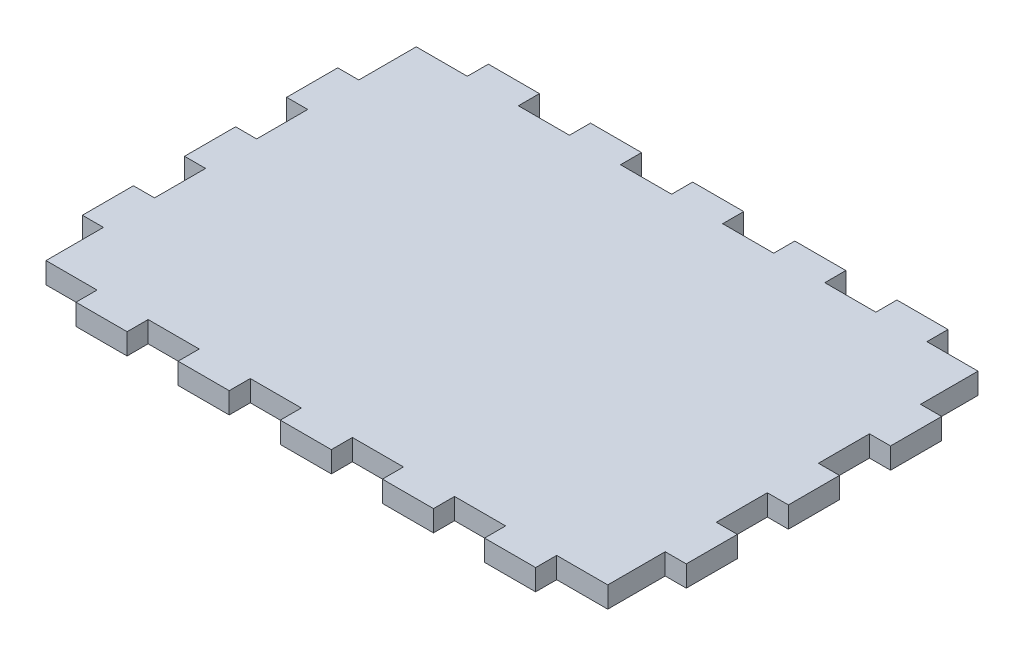
from build123d import *

# Parameters (mm, degrees)
ESQUISSE4_W                    = 88
ESQUISSE4_H                    = 58
BOSS_EXTRU_3_DEPTH             = 3.3
ESQUISSE5_W                    = 8
ESQUISSE5_H                    = 3.3
BOSS_EXTRU_6_DEPTH             = 3.3
R_P_TITION_LIN_AIRE2_COUNT     = 3
R_P_TITION_LIN_AIRE2_PITCH     = 16
R_P_TITION_LIN_AIRE2_COL_COUNT = 3
R_P_TITION_LIN_AIRE2_COL_PITCH = 16
SYM_TRIE1_COPY_1_SKETCH_W      = 8
SYM_TRIE1_COPY_1_SKETCH_H      = 3.3
SYM_TRIE1_COPY_1_DEPTH         = 3.3
SYM_TRIE1_COPY_2_SKETCH_W      = 8
SYM_TRIE1_COPY_2_SKETCH_H      = 3.3
SYM_TRIE1_COPY_2_DEPTH         = 3.3
SYM_TRIE1_COPY_3_SKETCH_W      = 8
SYM_TRIE1_COPY_3_SKETCH_H      = 3.3
SYM_TRIE1_COPY_3_DEPTH         = 3.3
SYM_TRIE1_COPY_4_SKETCH_W      = 8
SYM_TRIE1_COPY_4_SKETCH_H      = 3.3
SYM_TRIE1_COPY_4_DEPTH         = 3.3
ESQUISSE6_W                    = 3.3
ESQUISSE6_H                    = 8
BOSS_EXTRU_7_DEPTH             = 3.3
R_P_TITION_LIN_AIRE3_COUNT     = 2
R_P_TITION_LIN_AIRE3_PITCH     = 16
R_P_TITION_LIN_AIRE3_COL_COUNT = 2
R_P_TITION_LIN_AIRE3_COL_PITCH = 16
SYM_TRIE2_COPY_1_SKETCH_W      = 3.3
SYM_TRIE2_COPY_1_SKETCH_H      = 8
SYM_TRIE2_COPY_1_DEPTH         = 3.3
SYM_TRIE2_COPY_2_SKETCH_W      = 3.3
SYM_TRIE2_COPY_2_SKETCH_H      = 8
SYM_TRIE2_COPY_2_DEPTH         = 3.3


with BuildPart() as part:
    # Esquisse4 → Boss.-Extru.3 (new body)
    with BuildSketch(Plane(origin=(0, 0, 0), x_dir=(1, 0, 0), z_dir=(0, 1, 0))):
        Rectangle(ESQUISSE4_W, ESQUISSE4_H)
    extrude(amount=BOSS_EXTRU_3_DEPTH)

    # Esquisse5 → Boss.-Extru.6 (add)
    with BuildSketch(Plane.XZ):
        with Locations((0, 30.65)):
            Rectangle(ESQUISSE5_W, ESQUISSE5_H)
    boss_extru_6 = extrude(amount=-BOSS_EXTRU_6_DEPTH)

    # Répétition linéaire2: Boss.-Extru.6 ×3
    with Locations(*[(-i * R_P_TITION_LIN_AIRE2_PITCH, 0, 0) for i in range(1, R_P_TITION_LIN_AIRE2_COUNT)]):
        add(boss_extru_6)

    # Répétition linéaire2 col: Boss.-Extru.6 ×3
    with Locations(*[(i * R_P_TITION_LIN_AIRE2_COL_PITCH, 0, 0) for i in range(1, R_P_TITION_LIN_AIRE2_COL_COUNT)]):
        add(boss_extru_6)

    # Symétrie1: Boss.-Extru.6 across plane
    add(boss_extru_6.mirror(Plane.XY))

    # Symétrie1 copy 1 sketch → Symétrie1 copy 1 (add)
    with BuildSketch(Plane(origin=(-16, 0, 0), x_dir=(1, 0, 0), z_dir=(0, -1, 0))):
        with Locations((0, -30.65)):
            Rectangle(SYM_TRIE1_COPY_1_SKETCH_W, SYM_TRIE1_COPY_1_SKETCH_H)
    extrude(amount=-SYM_TRIE1_COPY_1_DEPTH)

    # Symétrie1 copy 2 sketch → Symétrie1 copy 2 (add)
    with BuildSketch(Plane(origin=(-32, 0, 0), x_dir=(1, 0, 0), z_dir=(0, -1, 0))):
        with Locations((0, -30.65)):
            Rectangle(SYM_TRIE1_COPY_2_SKETCH_W, SYM_TRIE1_COPY_2_SKETCH_H)
    extrude(amount=-SYM_TRIE1_COPY_2_DEPTH)

    # Symétrie1 copy 3 sketch → Symétrie1 copy 3 (add)
    with BuildSketch(Plane(origin=(16, 0, 0), x_dir=(1, 0, 0), z_dir=(0, -1, 0))):
        with Locations((0, -30.65)):
            Rectangle(SYM_TRIE1_COPY_3_SKETCH_W, SYM_TRIE1_COPY_3_SKETCH_H)
    extrude(amount=-SYM_TRIE1_COPY_3_DEPTH)

    # Symétrie1 copy 4 sketch → Symétrie1 copy 4 (add)
    with BuildSketch(Plane(origin=(32, 0, 0), x_dir=(1, 0, 0), z_dir=(0, -1, 0))):
        with Locations((0, -30.65)):
            Rectangle(SYM_TRIE1_COPY_4_SKETCH_W, SYM_TRIE1_COPY_4_SKETCH_H)
    extrude(amount=-SYM_TRIE1_COPY_4_DEPTH)

    # Esquisse6 → Boss.-Extru.7 (add)
    with BuildSketch(Plane.XZ):
        with Locations((-45.65, 0)):
            Rectangle(ESQUISSE6_W, ESQUISSE6_H)
    boss_extru_7 = extrude(amount=-BOSS_EXTRU_7_DEPTH)

    # Répétition linéaire3: Boss.-Extru.7 ×2
    with Locations(*[(0, 0, i * R_P_TITION_LIN_AIRE3_PITCH) for i in range(1, R_P_TITION_LIN_AIRE3_COUNT)]):
        add(boss_extru_7)

    # Répétition linéaire3 col: Boss.-Extru.7 ×2
    with Locations(*[(0, 0, -i * R_P_TITION_LIN_AIRE3_COL_PITCH) for i in range(1, R_P_TITION_LIN_AIRE3_COL_COUNT)]):
        add(boss_extru_7)

    # Symétrie2: Boss.-Extru.7 across plane
    add(boss_extru_7.mirror(Plane(origin=(0, 0, 0), x_dir=(0, 0, 1), z_dir=(1, 0, 0))))

    # Symétrie2 copy 1 sketch → Symétrie2 copy 1 (add)
    with BuildSketch(Plane(origin=(0, 0, 16), x_dir=(-1, 0, 0), z_dir=(0, -1, 0))):
        with Locations((-45.65, 0)):
            Rectangle(SYM_TRIE2_COPY_1_SKETCH_W, SYM_TRIE2_COPY_1_SKETCH_H)
    extrude(amount=-SYM_TRIE2_COPY_1_DEPTH)

    # Symétrie2 copy 2 sketch → Symétrie2 copy 2 (add)
    with BuildSketch(Plane(origin=(0, 0, -16), x_dir=(-1, 0, 0), z_dir=(0, -1, 0))):
        with Locations((-45.65, 0)):
            Rectangle(SYM_TRIE2_COPY_2_SKETCH_W, SYM_TRIE2_COPY_2_SKETCH_H)
    extrude(amount=-SYM_TRIE2_COPY_2_DEPTH)


solid = part.part
